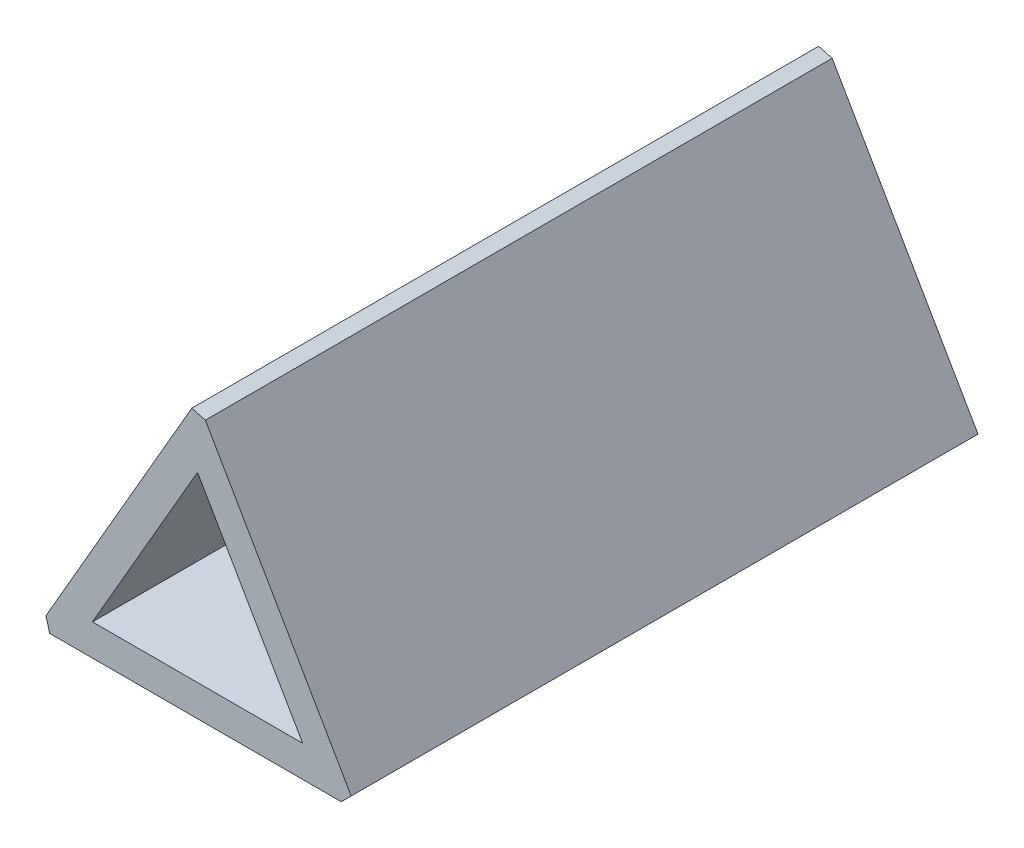
from build123d import *
from OCP.BRepFilletAPI import BRepFilletAPI_MakeChamfer

# Parameters (mm, degrees)
BOSS_EXTRUDE1_DEPTH = 40
CHAMFER1_SIZE       = 1
CHAMFER1_SIZE2      = 0.732050808


with BuildPart() as part:
    # Sketch1 → Boss-Extrude1 (new body)
    with BuildSketch(Plane.XY):
        Polygon((0, 11.745081595), (-10.171539031, -5.872540798), (10.171539031, -5.872540798), align=None)
        Polygon((0, 7.745081595), (-6.707437416, -3.872540798), (6.707437416, -3.872540798), align=None, mode=Mode.SUBTRACT)
    extrude(amount=BOSS_EXTRUDE1_DEPTH)

    # Chamfer1: one chamfer whose edges measure the first distance from different faces: ONE call of the kernel's chamfer builder (chamfer() names one face for all edges)
    chamfer1_edges_1 = [part.edges().sort_by_distance(p)[0] for p in [
        (10.171539031, -5.872540798, 20),
    ]]
    chamfer1_side_1 = [part.faces().sort_by_distance(p)[0] for p in [
        (0, -5.872540798, 20),
    ]]
    chamfer1_edges_2 = [part.edges().sort_by_distance(p)[0] for p in [
        (-10.171539031, -5.872540798, 20),
    ]]
    chamfer1_side_2 = [part.faces().sort_by_distance(p)[0] for p in [
        (-5.085769515, 2.936270399, 20),
    ]]
    chamfer1_edges_3 = [part.edges().sort_by_distance(p)[0] for p in [
        (0, 11.745081595, 20),
    ]]
    chamfer1_side_3 = [part.faces().sort_by_distance(p)[0] for p in [
        (5.085769515, 2.936270399, 20),
    ]]
    chamfer1 = BRepFilletAPI_MakeChamfer(part.part.solid().wrapped)
    for e in chamfer1_edges_1:
        chamfer1.Add(CHAMFER1_SIZE, CHAMFER1_SIZE2, e.wrapped, chamfer1_side_1[0].wrapped)  # the first distance lies on this face
    for e in chamfer1_edges_2:
        chamfer1.Add(CHAMFER1_SIZE, CHAMFER1_SIZE2, e.wrapped, chamfer1_side_2[0].wrapped)  # the first distance lies on this face
    for e in chamfer1_edges_3:
        chamfer1.Add(CHAMFER1_SIZE, CHAMFER1_SIZE2, e.wrapped, chamfer1_side_3[0].wrapped)  # the first distance lies on this face
    add(Compound.cast(chamfer1.Shape()), mode=Mode.REPLACE)


solid = part.part
